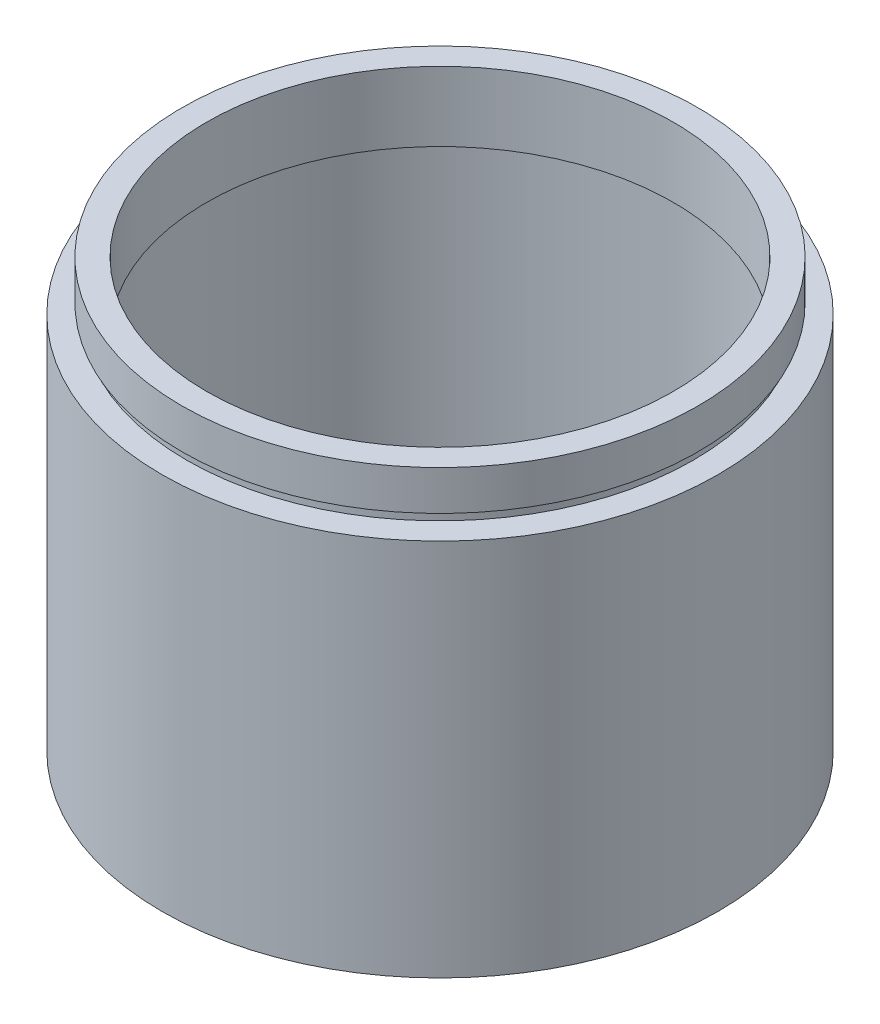
from build123d import *


with BuildPart() as part:
    # 草图1 → 旋转1 (revolve)
    with BuildSketch(Plane.XY, mode=Mode.PRIVATE) as revolve_1_sk:
        Polygon((23.5, 43.1), (26, 43.1), (26, 39.1), (25.5, 39.1), (25.5, 38.1), (28, 38.1), (28, 0), (25.5, 0), (25.5, 35.1), (26.1, 35.1), (26.1, 36.1), (23.5, 36.1), align=None)
    revolve(revolve_1_sk.sketch.rotate(Axis((0, 161.376166943, 0), (0, -1, 0)), 90), axis=Axis((0, 161.376166943, 0), (0, -1, 0)))  # turned: the seam where the file's is


solid = part.part
